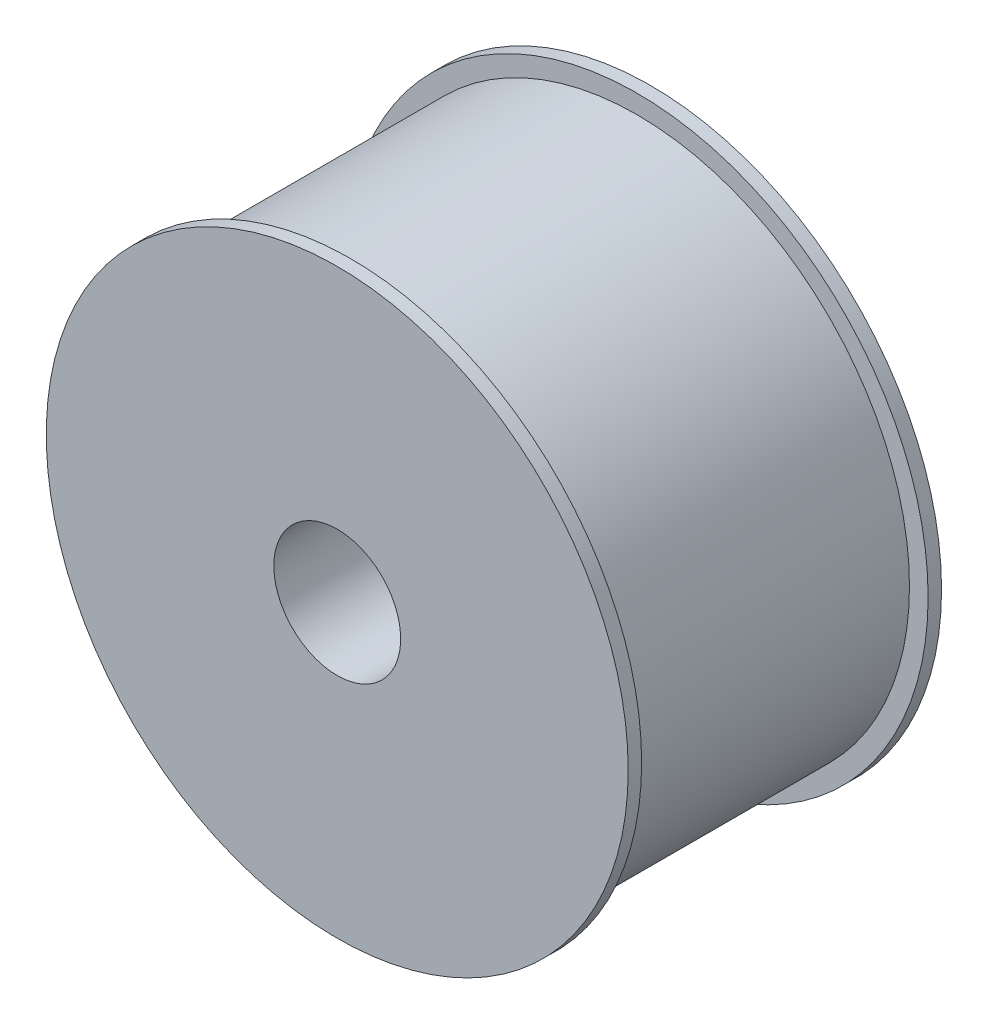
from build123d import *

# Parameters (mm, degrees)
CROQUIS1_R              = 36.5
SALIENTE_EXTRUIR1_DEPTH = 38.4
CROQUIS2_R              = 39
SALIENTE_EXTRUIR2_DEPTH = 1.8
CROQUIS3_R              = 8.5
CORTAR_EXTRUIR1_DEPTH   = 43


with BuildPart() as part:
    # Croquis1 → Saliente-Extruir1 (new body)
    with BuildSketch(Plane.XY):
        Circle(CROQUIS1_R)
    extrude(amount=SALIENTE_EXTRUIR1_DEPTH)

    # Croquis2 → Saliente-Extruir2 (add)
    with BuildSketch(Plane.XY.offset(38.4)):
        Circle(CROQUIS2_R)
    saliente_extruir2 = extrude(amount=SALIENTE_EXTRUIR2_DEPTH)

    # Simetría1: Saliente-Extruir2 across plane
    add(saliente_extruir2.mirror(Plane(origin=(0, 0, 19.2), x_dir=(1, 0, 0), z_dir=(0, 0, -1))))

    # Croquis3 → Cortar-Extruir1 (cut, through all)
    with BuildSketch(Plane(origin=(0, 0, -1.8), x_dir=(-1, 0, 0), z_dir=(0, 0, -1))):
        Circle(CROQUIS3_R)
    extrude(amount=-CORTAR_EXTRUIR1_DEPTH, mode=Mode.SUBTRACT)


solid = part.part
